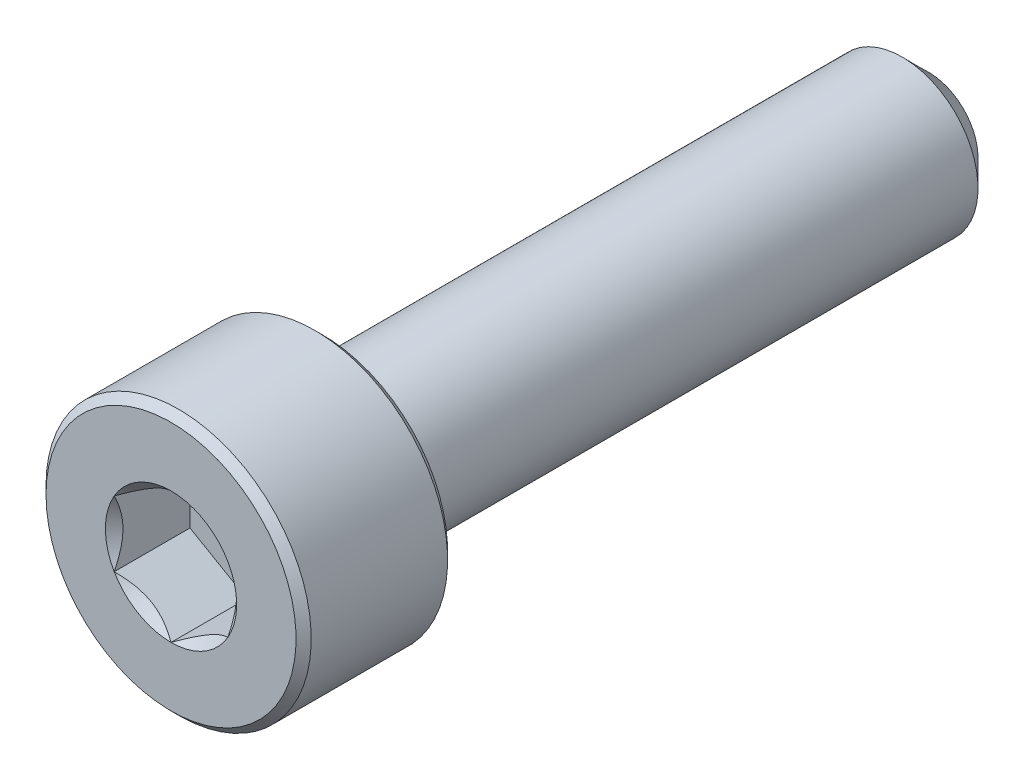
from build123d import *

# Parameters (mm, degrees)
CUT_EXTRUDE1_START = -2
CUT_EXTRUDE1_DEPTH = 2
SKETCH4_R          = 1.732050808
CUT_EXTRUDE2_DEPTH = 0.5
CUT_EXTRUDE2_TAPER = 45


with BuildPart() as part:
    # Sketch2 → Revolve1 (revolve)
    with BuildSketch(Plane(origin=(0, 0, 0), x_dir=(0, 0, -1), z_dir=(1, 0, 0))):
        Polygon((-9.8, 3.5), (-6.2, 3.5), (-6, 3.3), (-6, 2), (9.3, 2), (10, 1.3), (10, 0), (-10, 0), (-10, 3.3), align=None)
    revolve(axis=Axis((0, 0, -10), (0, 0, 1)))

    # Sketch3 → Cut-Extrude1 (cut)
    with BuildSketch(Plane.XY.offset(10).offset(CUT_EXTRUDE1_START)):
        Polygon((0, 1.732050808), (-1.5, 0.866025404), (-1.5, -0.866025404), (0, -1.732050808), (1.5, -0.866025404), (1.5, 0.866025404), align=None)
    extrude(amount=CUT_EXTRUDE1_DEPTH, mode=Mode.SUBTRACT)

    # Sketch4 → Cut-Extrude2 (cut)
    with BuildSketch(Plane.XY.offset(10)):
        Circle(SKETCH4_R)
    extrude(amount=-CUT_EXTRUDE2_DEPTH, taper=CUT_EXTRUDE2_TAPER, mode=Mode.SUBTRACT)


solid = part.part
